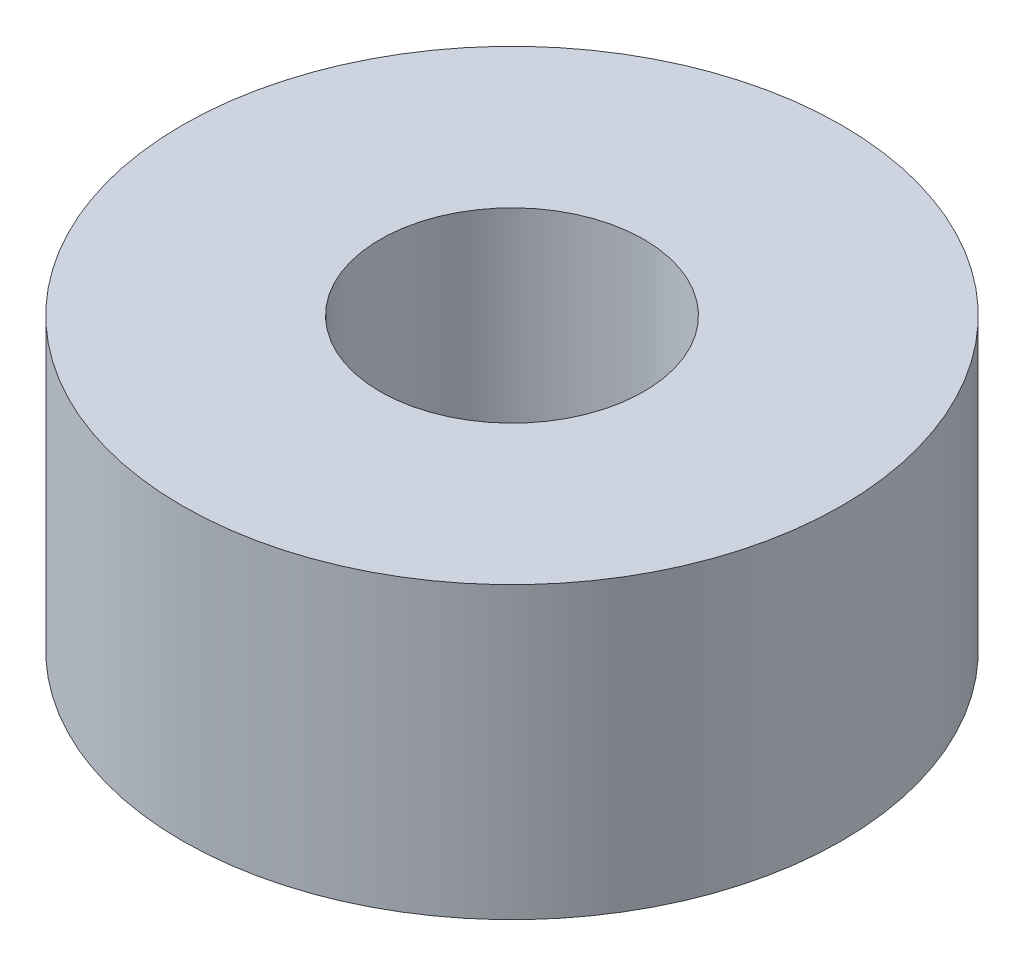
from build123d import *

# Parameters (mm, degrees)
SKETCH1_R           = 2.5
SKETCH1_R_2         = 1
BOSS_EXTRUDE1_DEPTH = 2.2


with BuildPart() as part:
    # Sketch1 → Boss-Extrude1 (new body)
    with BuildSketch(Plane(origin=(0, 0, 0), x_dir=(1, 0, 0), z_dir=(0, 1, 0))):
        Circle(SKETCH1_R)
        Circle(SKETCH1_R_2, mode=Mode.SUBTRACT)
    extrude(amount=BOSS_EXTRUDE1_DEPTH)


solid = part.part
